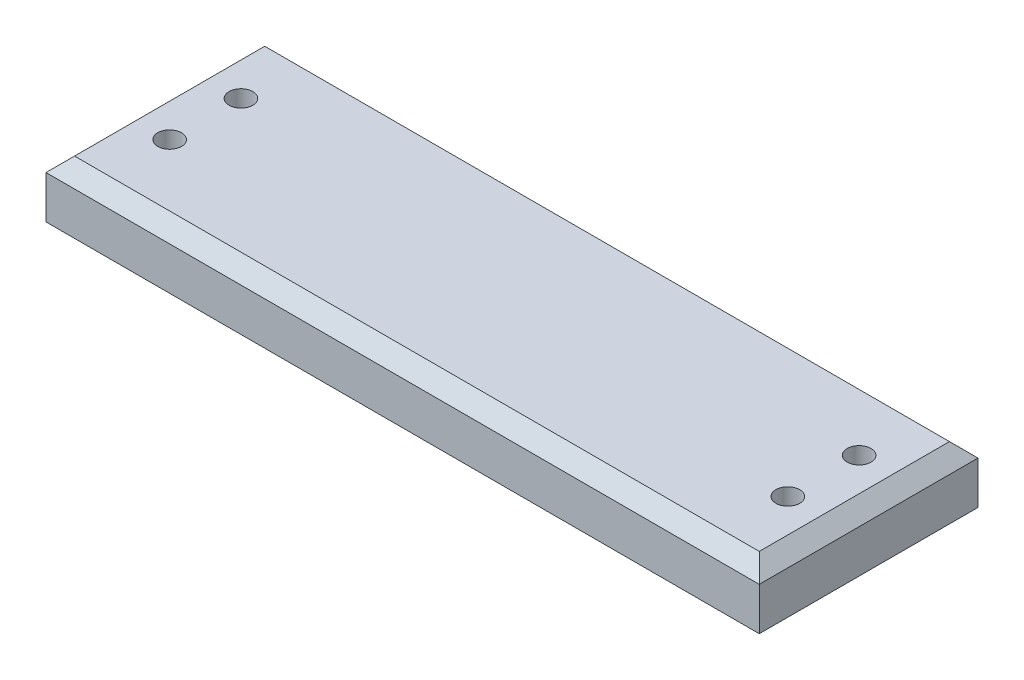
from build123d import *

# Parameters (mm, degrees)
SKETCH1_W           = 3810
SKETCH1_H           = 1168.4
BOSS_EXTRUDE1_DEPTH = 304.8
CHAMFER1_SIZE       = 76.2
SKETCH3_R           = 63.5
CUT_EXTRUDE1_DEPTH  = 305.8
CHAMFER2_SIZE       = 38.1


with BuildPart() as part:
    # Sketch1 → Boss-Extrude1 (new body)
    with BuildSketch(Plane(origin=(0, 0, 0), x_dir=(1, 0, 0), z_dir=(0, 1, 0))):
        Rectangle(SKETCH1_W, SKETCH1_H)
    extrude(amount=BOSS_EXTRUDE1_DEPTH)

    # Chamfer1
    chamfer1_edges = [part.edges().sort_by_distance(p)[0] for p in [
        (-1905, 304.8, 0),
        (0, 304.8, 584.2),
        (1905, 304.8, 0),
        (0, 304.8, -584.2),
    ]]
    chamfer(chamfer1_edges, length=CHAMFER1_SIZE)

    # Sketch3 → Cut-Extrude1 (cut, through all)
    with BuildSketch(Plane(origin=(0, 304.8, 0), x_dir=(1, 0, 0), z_dir=(0, 1, 0))):
        with Locations(Location((-1651, -177.8, 0), (0, 0, 270))):  # turned: the seam where the file's is
            Circle(SKETCH3_R)
        with Locations(Location((-1651, 203.2, 0), (0, 0, 270))):  # turned: the seam where the file's is
            Circle(SKETCH3_R)
        with Locations(Location((1651, 203.2, 0), (0, 0, 270))):  # turned: the seam where the file's is
            Circle(SKETCH3_R)
        with Locations(Location((1651, -177.8, 0), (0, 0, 270))):  # turned: the seam where the file's is
            Circle(SKETCH3_R)
    extrude(amount=-CUT_EXTRUDE1_DEPTH, mode=Mode.SUBTRACT)

    # Chamfer2
    chamfer2_edges = [part.edges().sort_by_distance(p)[0] for p in [
        (-1651, 0, 114.3),
        (-1651, 0, -266.7),
        (1651, 0, -266.7),
        (1651, 0, 114.3),
    ]]
    chamfer(chamfer2_edges, length=CHAMFER2_SIZE)


solid = part.part
